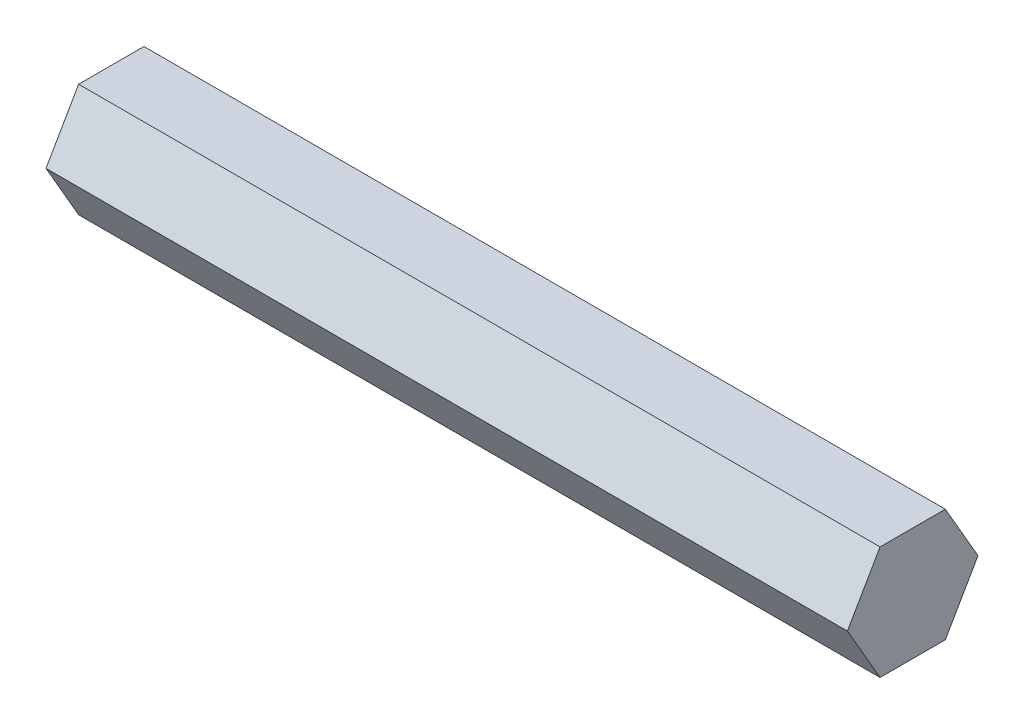
from build123d import *

# Parameters (mm, degrees)
BOSS_EXTRUDE1_DEPTH = 90


with BuildPart() as part:
    # Sketch1 → Boss-Extrude1 (new body)
    with BuildSketch(Plane(origin=(0, 0, 0), x_dir=(0, 0, -1), z_dir=(1, 0, 0))):
        Polygon((7.332348419, 0), (3.666174209, 6.35), (-3.666174209, 6.35), (-7.332348419, 0), (-3.666174209, -6.35), (3.666174209, -6.35), align=None)
    extrude(amount=BOSS_EXTRUDE1_DEPTH)


solid = part.part
